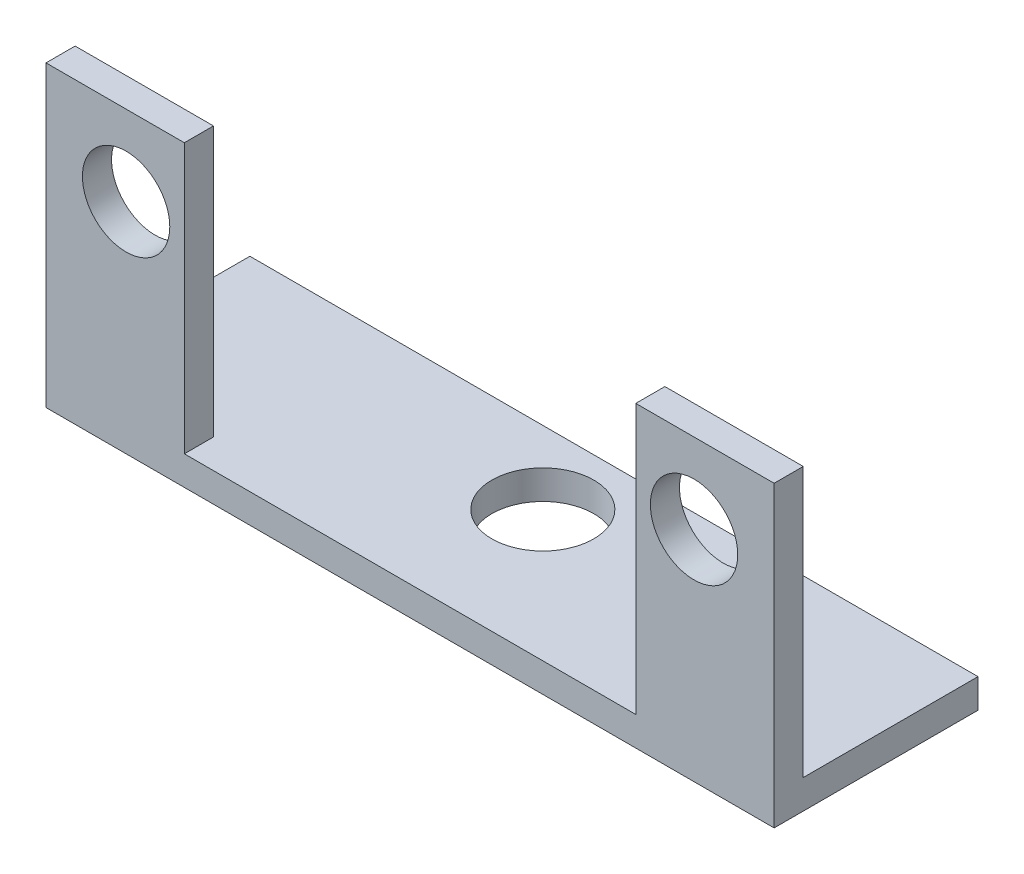
from build123d import *

# Parameters (mm, degrees)
ESBO_O1_R                = 1.5
RESSALTO_EXTRUS_O1_DEPTH = 1
ESBO_O2_W                = 25
ESBO_O2_H                = 1
RESSALTO_EXTRUS_O2_DEPTH = 6
ESBO_O3_R                = 1.75
CORTE_EXTRUS_O1_DEPTH    = 5


with BuildPart() as part:
    # Esboço1 → Ressalto-extrusão1 (new body)
    with BuildSketch(Plane.XY):
        Polygon((-2.930659551, 5.581459362), (-2.930659551, -4.668540638), (22.069340449, -4.668540638), (22.069340449, 5.581459362), (17.319340449, 5.581459362), (17.319340449, -3.668540638), (1.819340449, -3.668540638), (1.819340449, 5.581459362), align=None)
        with Locations((-0.180659551, 2.831459362)):
            Circle(ESBO_O1_R, mode=Mode.SUBTRACT)
        with Locations((19.319340449, 2.831459362)):
            Circle(ESBO_O1_R, mode=Mode.SUBTRACT)
    extrude(amount=RESSALTO_EXTRUS_O1_DEPTH)

    # Esboço2 → Ressalto-extrusão2 (add)
    with BuildSketch(Plane(origin=(0, 0, 0), x_dir=(-1, 0, 0), z_dir=(0, 0, -1))):
        with Locations((-9.569340449, -4.168540638)):
            Rectangle(ESBO_O2_W, ESBO_O2_H)
    extrude(amount=RESSALTO_EXTRUS_O2_DEPTH)

    # Esboço3 → Corte-extrusão1 (cut)
    with BuildSketch(Plane(origin=(0, -3.668540638, 0), x_dir=(1, 0, 0), z_dir=(0, 1, 0))):
        with Locations((9.627945133, 3.5)):
            Circle(ESBO_O3_R)
    extrude(amount=-CORTE_EXTRUS_O1_DEPTH, mode=Mode.SUBTRACT)


solid = part.part
